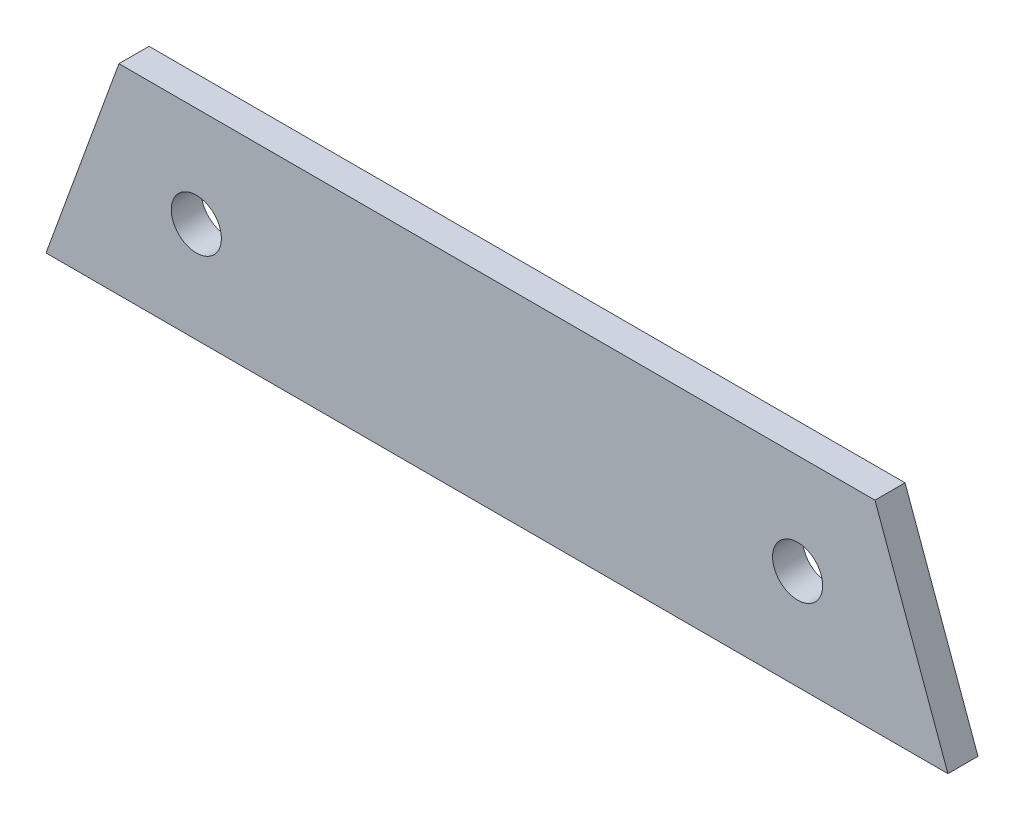
from build123d import *

# Parameters (mm, degrees)
CROQUIS1_R              = 2.5
SALIENTE_EXTRUIR1_DEPTH = 3


with BuildPart() as part:
    # Croquis1 → Saliente-Extruir1 (new body)
    with BuildSketch(Plane.XY):
        Polygon((-45, 0), (45, 0), (37.720595315, 20), (-37.720595315, 20), align=None)
        with Locations((-30, 10)):
            Circle(CROQUIS1_R, mode=Mode.SUBTRACT)
        with Locations((30, 10)):
            Circle(CROQUIS1_R, mode=Mode.SUBTRACT)
    extrude(amount=SALIENTE_EXTRUIR1_DEPTH)


solid = part.part
